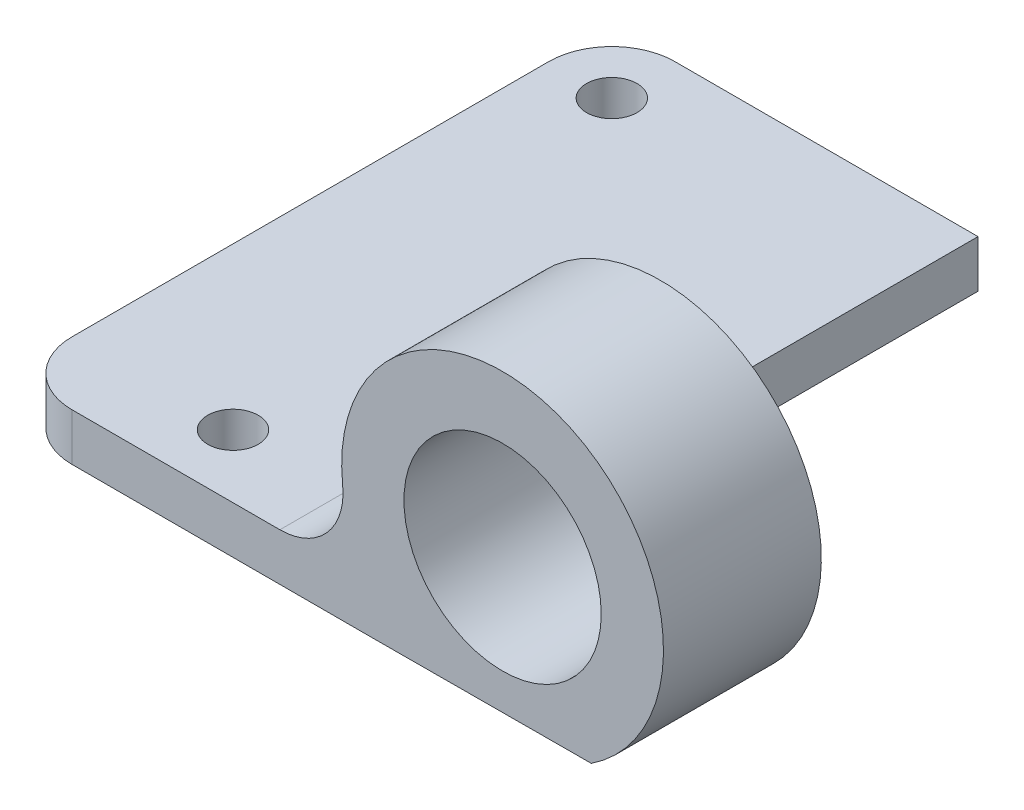
from build123d import *

# Parameters (mm, degrees)
SKETCH1_W           = 23.2
SKETCH1_H           = 38.2
SKETCH1_R           = 1.6
BOSS_EXTRUDE1_DEPTH = 3
FILLET1_R           = 4
SKETCH2_R           = 6.25
BOSS_EXTRUDE2_DEPTH = 10
FILLET2_R           = 4


with BuildPart() as part:
    # Sketch1 → Boss-Extrude1 (new body)
    with BuildSketch(Plane(origin=(0, 0, 0), x_dir=(1, 0, 0), z_dir=(0, 1, 0))):
        with Locations((7.60855083, -14.720520933)):
            Rectangle(SKETCH1_W, SKETCH1_H)
        with Locations((0.00855083, 0.379479067)):
            Circle(SKETCH1_R, mode=Mode.SUBTRACT)
        with Locations((6.20855083, -29.820520933)):
            Circle(SKETCH1_R, mode=Mode.SUBTRACT)
    extrude(amount=BOSS_EXTRUDE1_DEPTH)

    # Fillet1
    fillet1_edges = [part.edges().sort_by_distance(p)[0] for p in [
        (-3.99144917, 1.5, -4.379479067),
        (-3.99144917, 1.5, 33.820520933),
    ]]
    fillet(fillet1_edges, radius=FILLET1_R)

    # Sketch2 → Boss-Extrude2 (add)
    with BuildSketch(Plane.XY.offset(33.820520933)):
        with BuildLine():
            Line((19.20855083, 0), (32.911096752, 0.047304531))
            ThreePointArc((32.911096752, 0.047304531), (28.967391183, 18.604369594), (19.20855083, 2.335303477))
            Line((19.20855083, 2.335303477), (19.20855083, 0))
        make_face()
        with Locations((27.28855083, 8.55)):
            Circle(SKETCH2_R, mode=Mode.SUBTRACT)
    extrude(amount=-BOSS_EXTRUDE2_DEPTH)

    # Fillet2
    fillet2_edges = [part.edges().sort_by_distance(p)[0] for p in [
        (18.738325519, 3, 28.820520933),
    ]]
    fillet(fillet2_edges, radius=FILLET2_R)


solid = part.part
